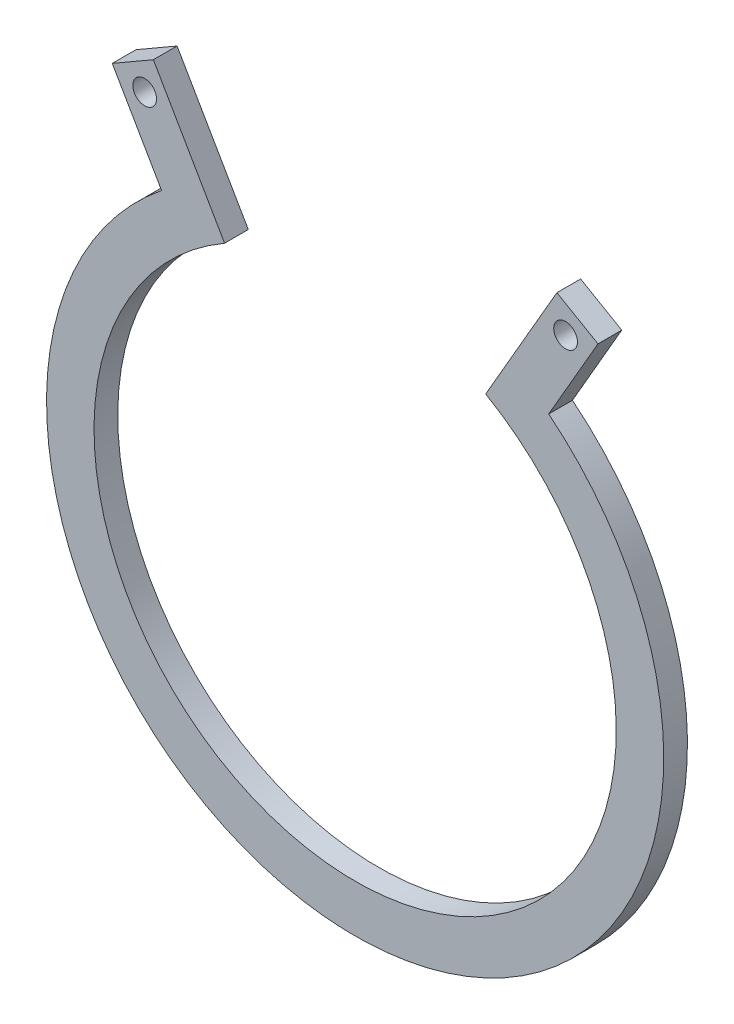
from build123d import *

# Parameters (mm, degrees)
SKETCH2_R           = 41.275
SKETCH2_R_2         = 38.1
SKETCH2_R_3         = 34.925
BOSS_EXTRUDE1_DEPTH = 3.175
SKETCH3_R           = 1.5875
BOSS_EXTRUDE2_DEPTH = 3.175
CUT_EXTRUDE1_DEPTH  = 3.175


with BuildPart() as part:
    # Sketch2 → Boss-Extrude1 (new body)
    with BuildSketch(Plane.XY):
        Circle(SKETCH2_R)
        Circle(SKETCH2_R_2, mode=Mode.SUBTRACT)
        Circle(SKETCH2_R_2)
        Circle(SKETCH2_R_3, mode=Mode.SUBTRACT)
    extrude(amount=BOSS_EXTRUDE1_DEPTH)

    # Sketch3 → Boss-Extrude2 (add)
    with BuildSketch(Plane.XY.offset(3.175)):
        with BuildLine():
            ThreePointArc((-25.891068033, 32.144645295), (-23.333836091, 34.046405365), (-20.6375, 35.745198541))
            Line((-20.6375, 35.745198541), (-26.9875, 46.743721169))
            Line((-26.9875, 46.743721169), (-32.486761314, 43.568721169))
            Line((-32.486761314, 43.568721169), (-26.136761314, 32.570198541))
            Line((-26.136761314, 32.570198541), (-25.891068033, 32.144645295))
        make_face()
        with Locations((-28.149630657, 42.406590512)):
            Circle(SKETCH3_R, mode=Mode.SUBTRACT)
        with BuildLine():
            Line((26.9875, 46.743721169), (20.6375, 35.745198541))
            ThreePointArc((20.6375, 35.745198541), (23.333836091, 34.046405365), (25.891068033, 32.144645295))
            Line((25.891068033, 32.144645295), (26.136761314, 32.570198541))
            Line((26.136761314, 32.570198541), (32.486761314, 43.568721169))
            Line((32.486761314, 43.568721169), (26.9875, 46.743721169))
        make_face()
        with Locations((28.149630657, 42.406590512)):
            Circle(SKETCH3_R, mode=Mode.SUBTRACT)
    extrude(amount=-BOSS_EXTRUDE2_DEPTH)

    # Sketch5 → Cut-Extrude1 (cut)
    with BuildSketch(Plane.XY.offset(3.175)):
        with BuildLine():
            Line((-20.6375, 35.745198541), (0, 0))
            Line((0, 0), (20.6375, 35.745198541))
            ThreePointArc((20.6375, 35.745198541), (0, 41.275), (-20.6375, 35.745198541))
        make_face()
    extrude(amount=-CUT_EXTRUDE1_DEPTH, mode=Mode.SUBTRACT)


solid = part.part
